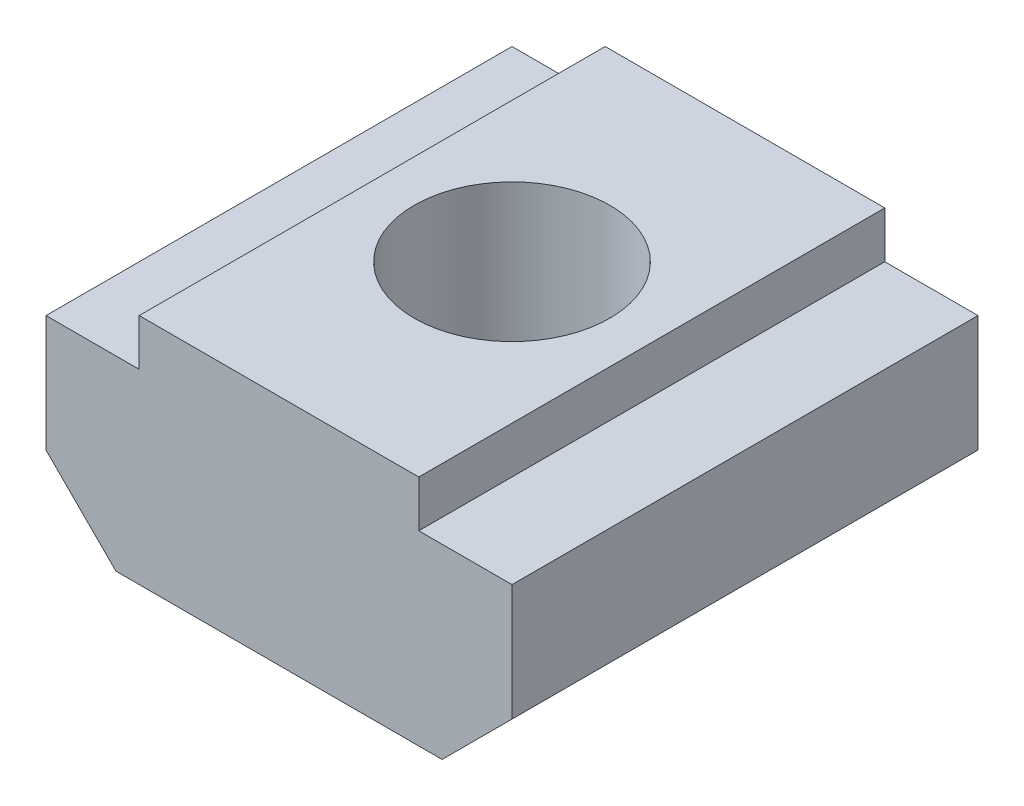
from build123d import *

# Parameters (mm, degrees)
SKETCH1_W           = 6
SKETCH1_H           = 4
SKETCH1_H_2         = 1
BOSS_EXTRUDE1_DEPTH = 5
SKETCH2_R           = 2.1
CUT_EXTRUDE1_DEPTH  = 6


with BuildPart() as part:
    # Sketch1 → Boss-Extrude1 (new body, symmetric)
    with BuildSketch(Plane.XY):
        Polygon((-5, 1.5), (-5, -1), (-3.5, -2.5), (-3, -2.5), (-3, 1.5), align=None)
        with Locations((0, -0.5)):
            Rectangle(SKETCH1_W, SKETCH1_H)
        with Locations((0, 2)):
            Rectangle(SKETCH1_W, SKETCH1_H_2)
        Polygon((3, 1.5), (3, -2.5), (3.5, -2.5), (5, -1), (5, 1.5), align=None)
    extrude(amount=BOSS_EXTRUDE1_DEPTH, both=True)

    # Sketch2 → Cut-Extrude1 (cut, through all)
    with BuildSketch(Plane(origin=(0, 2.5, 0), x_dir=(1, 0, 0), z_dir=(0, 1, 0))):
        Circle(SKETCH2_R)
    extrude(amount=-CUT_EXTRUDE1_DEPTH, mode=Mode.SUBTRACT)


solid = part.part
